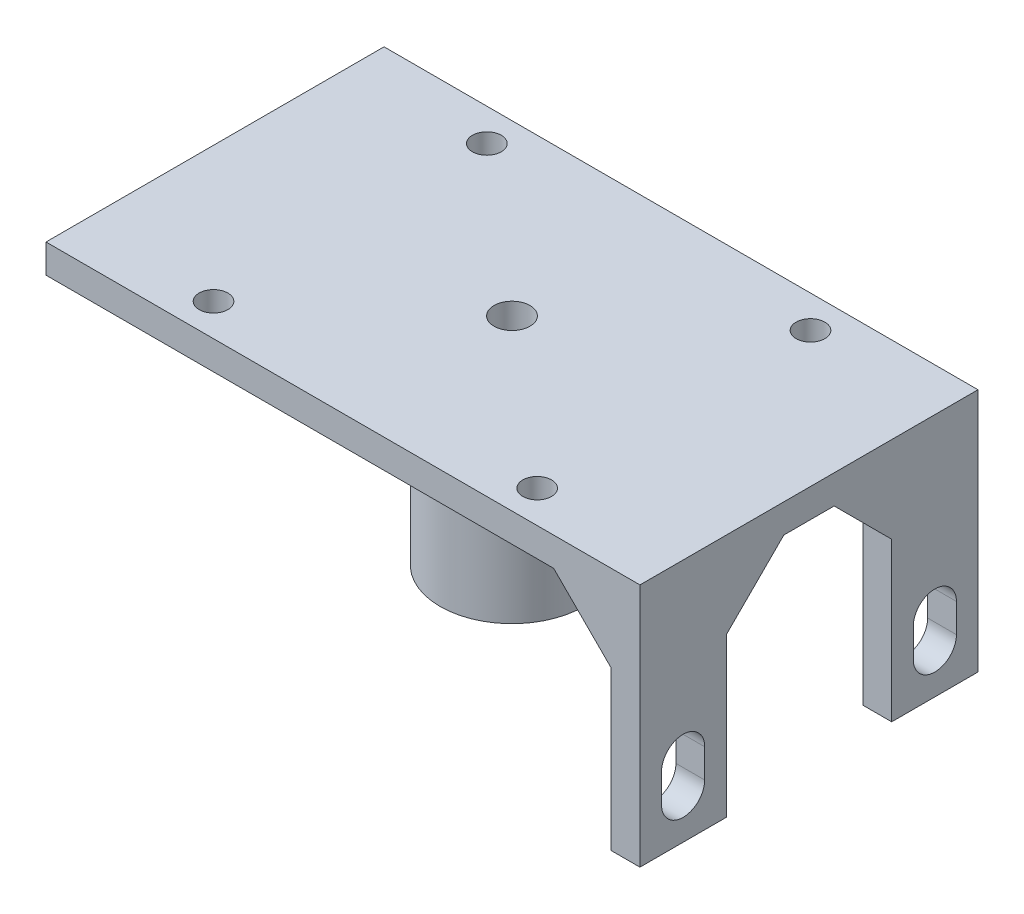
from build123d import *

# Parameters (mm, degrees)
CROQUIS3_W                   = 12
CROQUIS3_H                   = 29.99
SALIENTE_EXTRUIR1_DEPTH      = 4
SALIENTE_EXTRUIR1_2_DEPTH    = 4
CROQUIS4_W                   = 82.581060122
CROQUIS4_H                   = 47
SALIENTE_EXTRUIR2_DEPTH      = 4
SALIENTE_EXTRUIR2_DEPTH_BACK = 0.0001
CROQUIS2_W                   = 7.5
CROQUIS2_H                   = 25.9999
CHAFL_N2_SIZE                = 8
CROQUIS5_R                   = 2
CROQUIS5_R_2                 = 2.5
CORTAR_EXTRUIR1_DEPTH        = 30.9899
CORTAR_EXTRUIR1_DEPTH_BACK   = 5.0001


with BuildPart() as part:
    # Croquis3 → Saliente-Extruir1 (new body)
    with BuildSketch(Plane.ZY.offset(-41.290530061)):
        with Locations((17.5, -14.995)):
            Rectangle(CROQUIS3_W, CROQUIS3_H)
        with BuildLine():
            ThreePointArc((14.5, -23.99), (17.5, -26.99), (20.5, -23.99))
            Line((20.5, -23.99), (20.5, -19.99))
            ThreePointArc((20.5, -19.99), (17.5, -16.99), (14.5, -19.99))
            Line((14.5, -19.99), (14.5, -23.99))
        make_face(mode=Mode.SUBTRACT)
    extrude(amount=SALIENTE_EXTRUIR1_DEPTH)



with BuildPart() as body_2:
    # Croquis3 → Saliente-Extruir1 2 (new body)
    with BuildSketch(Plane.ZY.offset(-41.290530061)):
        with Locations((-17.5, -14.995)):
            Rectangle(CROQUIS3_W, CROQUIS3_H)
        with BuildLine():
            Line((-14.5, -19.99), (-14.5, -23.99))
            ThreePointArc((-14.5, -23.99), (-17.5, -26.99), (-20.5, -23.99))
            Line((-20.5, -23.99), (-20.5, -19.99))
            ThreePointArc((-20.5, -19.99), (-17.5, -16.99), (-14.5, -19.99))
        make_face(mode=Mode.SUBTRACT)
    extrude(amount=SALIENTE_EXTRUIR1_2_DEPTH)


with BuildPart() as part_1:
    add(part.part)

    add(body_2.part)  # Saliente-Extruir2 merges body 2
    # Croquis4 → Saliente-Extruir2 (add, two sides)
    with BuildSketch(Plane(origin=(0, 0, 0), x_dir=(1, 0, 0), z_dir=(0, 1, 0))) as saliente_extruir2_sk:
        Rectangle(CROQUIS4_W, CROQUIS4_H)
    extrude(amount=SALIENTE_EXTRUIR2_DEPTH)
    extrude(saliente_extruir2_sk.sketch, amount=-SALIENTE_EXTRUIR2_DEPTH_BACK)

    # Croquis2 → Revolución2 (revolve)
    with BuildSketch(Plane.XY):
        with Locations((-6.25, -13.00005)):
            Rectangle(CROQUIS2_W, CROQUIS2_H)
    revolve(axis=Axis((0, 0, 0), (0, -1, 0)))

    # Chaflán2
    chafl_n2_edges = [part_1.edges().sort_by_distance(p)[0] for p in [
        (39.290530061, -0.0001, 11.5),
        (37.290530061, -0.0001, 17.5),
        (39.290530061, -0.0001, -11.5),
        (37.290530061, -0.0001, -17.5),
        (10, -0.0001, 0),
    ]]
    chamfer(chafl_n2_edges, length=CHAFL_N2_SIZE)

    # Croquis5 → Cortar-Extruir1 (cut, two sides)
    with BuildSketch(Plane.XZ.offset(0.0001)) as cortar_extruir1_sk:
        with Locations((-22.5, 19)):
            Circle(CROQUIS5_R)
        with Locations((22.5, 19)):
            Circle(CROQUIS5_R)
        with Locations((22.5, -19)):
            Circle(CROQUIS5_R)
        with Locations((-22.5, -19)):
            Circle(CROQUIS5_R)
        Circle(CROQUIS5_R_2)
    extrude(amount=CORTAR_EXTRUIR1_DEPTH, mode=Mode.SUBTRACT)
    extrude(cortar_extruir1_sk.sketch, amount=-CORTAR_EXTRUIR1_DEPTH_BACK, mode=Mode.SUBTRACT)


solid = part_1.part
